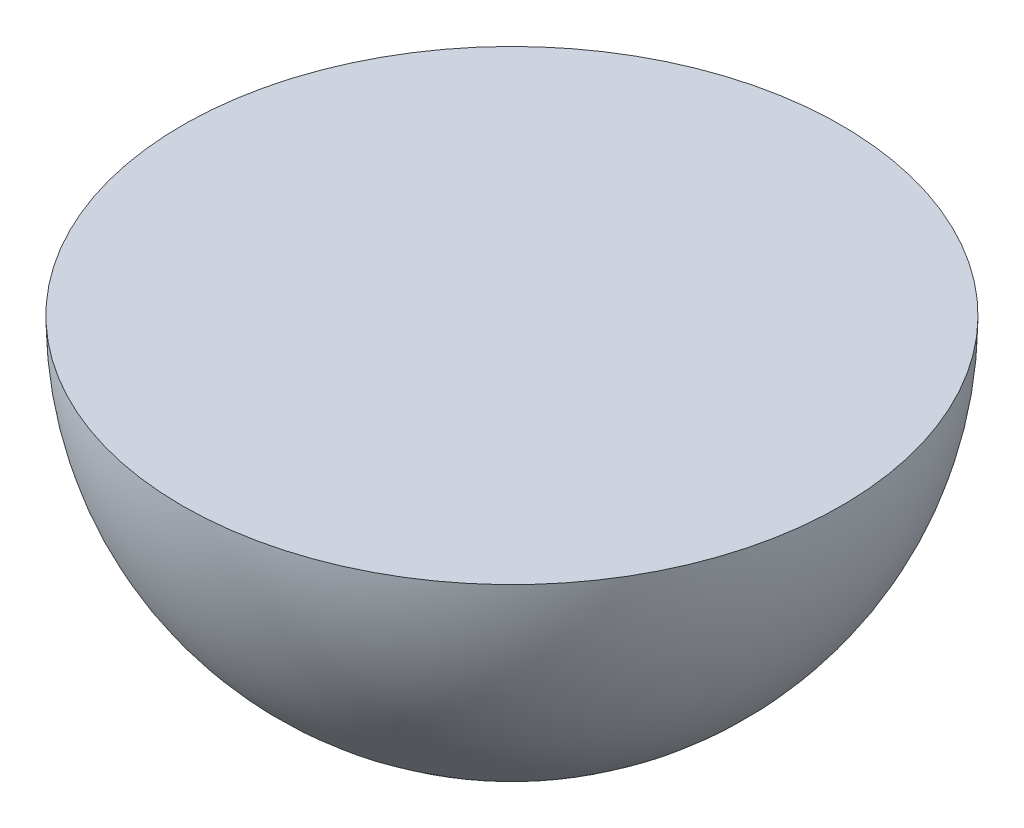
from build123d import *

# Parameters (mm, degrees)
REVOLVE1_ANGLE = 180


with BuildPart() as part:
    # Sketch2 → Revolve1 (revolve)
    with BuildSketch(Plane(origin=(0, 0, 0), x_dir=(1, 0, 0), z_dir=(0, 1, 0))):
        with BuildLine():
            Line((0, 71.755), (0, -71.755))
            ThreePointArc((0, -71.755), (-71.755, 0), (0, 71.755))
        make_face()
    revolve(axis=Axis((0, 0, -71.755), (0, 0, 1)), revolution_arc=REVOLVE1_ANGLE)


solid = part.part
